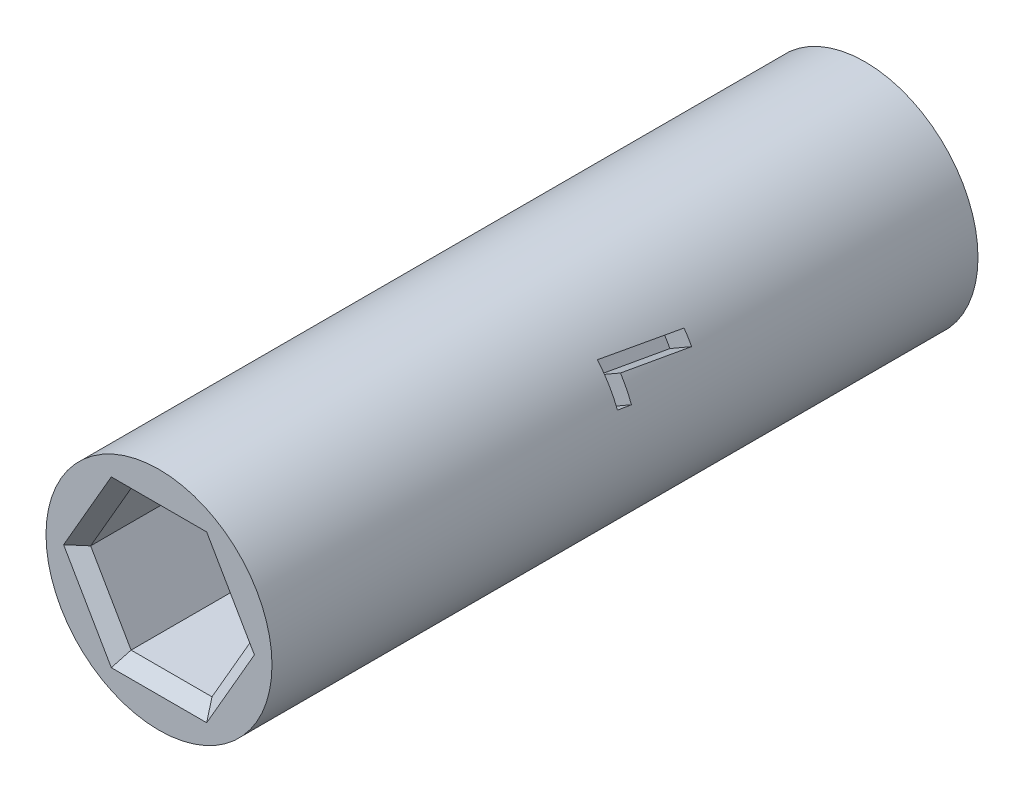
from build123d import *

# Parameters (mm, degrees)
SKETCH1_W          = 4.5
SKETCH1_H          = 28.11709914
CUT_EXTRUDE1_DEPTH = 7
CUT_EXTRUDE2_DEPTH = 7
CHAMFER1_SIZE      = 0.5
CUT_EXTRUDE3_DEPTH = 1


with BuildPart() as part:
    # Sketch1 → Revolve-Thin1 (revolve)
    with BuildSketch(Plane(origin=(0, 0, 0), x_dir=(1, 0, 0), z_dir=(0, 1, 0))):
        with Locations((2.25, 31.55854957)):
            Rectangle(SKETCH1_W, SKETCH1_H)
    revolve(axis=Axis((0, 0, 0), (0, 0, -1)))

    # Sketch2 → Cut-Extrude1 (cut)
    with BuildSketch(Plane.XY.offset(-17.5)):
        Polygon((1.610807251, 2.79), (-1.610807251, 2.79), (-3.221614502, 0), (-1.610807251, -2.79), (1.610807251, -2.79), (3.221614502, 0), align=None)
    extrude(amount=-CUT_EXTRUDE1_DEPTH, mode=Mode.SUBTRACT)

    # Sketch3 → Cut-Extrude2 (cut)
    with BuildSketch(Plane(origin=(0, 0, -45.61709914), x_dir=(-1, 0, 0), z_dir=(0, 0, -1))):
        Polygon((1.610807251, 2.79), (-1.610807251, 2.79), (-3.221614502, 0), (-1.610807251, -2.79), (1.610807251, -2.79), (3.221614502, 0), align=None)
    extrude(amount=-CUT_EXTRUDE2_DEPTH, mode=Mode.SUBTRACT)

    # Chamfer1
    chamfer1_edges = [part.edges().sort_by_distance(p)[0] for p in [
        (2.416210877, 1.395, -17.5),
        (0, 2.79, -17.5),
        (-2.416210877, 1.395, -17.5),
        (-2.416210877, -1.395, -17.5),
        (0, -2.79, -17.5),
        (2.416210877, -1.395, -17.5),
        (-2.416210877, 1.395, -45.61709914),
        (0, 2.79, -45.61709914),
        (2.416210877, 1.395, -45.61709914),
        (2.416210877, -1.395, -45.61709914),
        (0, -2.79, -45.61709914),
        (-2.416210877, -1.395, -45.61709914),
    ]]
    chamfer(chamfer1_edges, length=CHAMFER1_SIZE)

    # Sketch4 → Cut-Extrude3 (cut)
    with BuildSketch(Plane(origin=(3.897114317, 2.25, 0), x_dir=(0, 0, -1), z_dir=(0.866025404, 0.5, 0))):
        Polygon((34.73354957, 0.409595353), (34.73354957, -0.166636619), (32.087716237, 0.204797676), (32.087716237, -0.773397436), (31.55854957, -0.704707532), (31.55854957, 0.854807692), align=None)
    extrude(amount=-CUT_EXTRUDE3_DEPTH, mode=Mode.SUBTRACT)


solid = part.part
